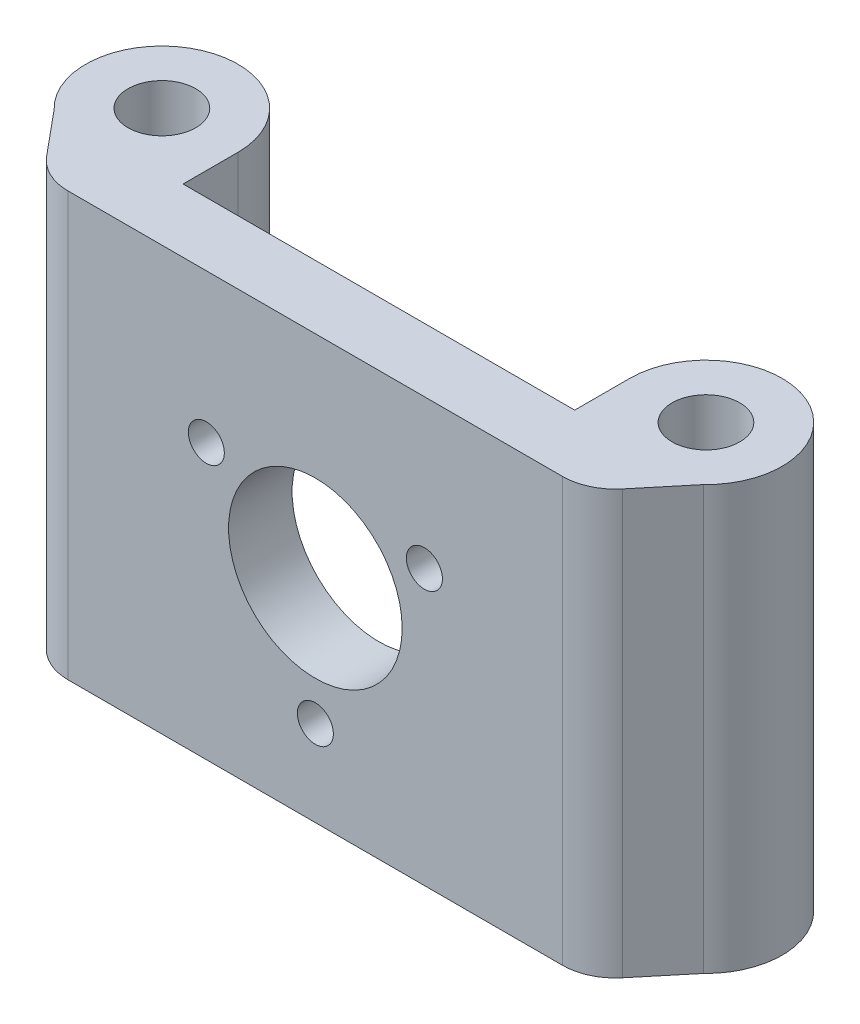
from build123d import *

# Parameters (mm, degrees)
SKETCH1_W           = 37
SKETCH1_H           = 6
SKETCH1_R           = 3.2
BOSS_EXTRUDE1_DEPTH = 20
CUT_EXTRUDE2_START  = -6
SKETCH2_R           = 8.2
SKETCH2_R_2         = 1.7
CUT_EXTRUDE2_DEPTH  = 7
FILLET1_R           = 5


with BuildPart() as part:
    # Sketch1 → Boss-Extrude1 (new body, symmetric)
    with BuildSketch(Plane(origin=(0, 0, 0), x_dir=(1, 0, 0), z_dir=(0, 1, 0))):
        with Locations((0, 3)):
            Rectangle(SKETCH1_W, SKETCH1_H)
        with BuildLine():
            Line((18.5, 6), (18.5, 0))
            Line((18.5, 0), (25.7, 0))
            Line((25.7, 0), (30.679959839, 6))
            ThreePointArc((30.679959839, 6), (28.527038128, 17.821771321), (18.5, 11.2))
            Line((18.5, 11.2), (18.5, 6))
        make_face()
        with Locations((25.7, 11.2)):
            Circle(SKETCH1_R, mode=Mode.SUBTRACT)
        with BuildLine():
            Line((-25.7, 0), (-18.5, 0))
            Line((-18.5, 0), (-18.5, 6))
            Line((-18.5, 6), (-18.5, 11.2))
            ThreePointArc((-18.5, 11.2), (-28.527038128, 17.821771321), (-30.679959839, 6))
            Line((-30.679959839, 6), (-25.7, 0))
        make_face()
        with Locations((-25.7, 11.2)):
            Circle(SKETCH1_R, mode=Mode.SUBTRACT)
    extrude(amount=BOSS_EXTRUDE1_DEPTH, both=True)

    # Sketch2 → Cut-Extrude2 (cut, through all)
    with BuildSketch(Plane.XY.offset(CUT_EXTRUDE2_START)):
        Circle(SKETCH2_R)
        with Locations((0, -11.893415545)):
            Circle(SKETCH2_R_2)
        with Locations((-10.3, 5.946707773)):
            Circle(SKETCH2_R_2)
        with Locations((10.3, 5.946707773)):
            Circle(SKETCH2_R_2)
    extrude(amount=CUT_EXTRUDE2_DEPTH, mode=Mode.SUBTRACT)

    # Fillet1
    fillet1_edges = [part.edges().sort_by_distance(p)[0] for p in [
        (25.7, 0, 0),
        (-25.7, 0, 0),
    ]]
    fillet(fillet1_edges, radius=FILLET1_R)


solid = part.part
